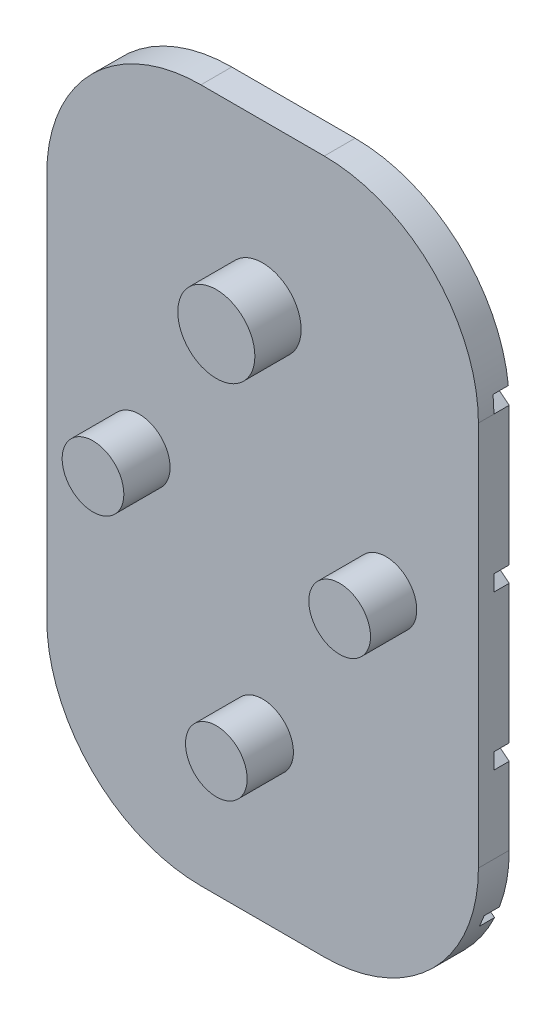
from build123d import *

# Parameters (mm, degrees)
CROQUIS1_R                = 2.5
CROQUIS1_R_2              = 2
SALIENTE_EXTRUIR1_DEPTH   = 2
CROQUIS2_R                = 2
SALIENTE_EXTRUIR2_DEPTH   = 3
SALIENTE_EXTRUIR2_2_DEPTH = 3
SALIENTE_EXTRUIR2_3_DEPTH = 3
CROQUIS2_R_2              = 2.5
SALIENTE_EXTRUIR2_4_DEPTH = 3
CORTAR_EXTRUIR1_DEPTH     = 1


with BuildPart() as part:
    # Croquis1 → Saliente-Extruir1 (new body)
    with BuildSketch(Plane.XY):
        with BuildLine():
            Line((-4, -22.5), (4, -22.5))
            ThreePointArc((4, -22.5), (11.071067812, -19.571067812), (14, -12.5))
            Line((14, -12.5), (14, 12.5))
            ThreePointArc((14, 12.5), (11.071067812, 19.571067812), (4, 22.5))
            Line((4, 22.5), (-4, 22.5))
            ThreePointArc((-4, 22.5), (-11.071067812, 19.571067812), (-14, 12.5))
            Line((-14, 12.5), (-14, -12.5))
            ThreePointArc((-14, -12.5), (-11.071067812, -19.571067812), (-4, -22.5))
        make_face()
        with Locations((0, 12)):
            Circle(CROQUIS1_R, mode=Mode.SUBTRACT)
        with Locations((0, -12)):
            Circle(CROQUIS1_R_2, mode=Mode.SUBTRACT)
        with Locations((-8, 0)):
            Circle(CROQUIS1_R_2, mode=Mode.SUBTRACT)
        with Locations((8, 0)):
            Circle(CROQUIS1_R_2, mode=Mode.SUBTRACT)
    extrude(amount=SALIENTE_EXTRUIR1_DEPTH)

    # Croquis3 → Cortar-Extruir1 (cut)
    with BuildSketch(Plane(origin=(0, 0, 0), x_dir=(-1, 0, 0), z_dir=(0, 0, -1))):
        with BuildLine():
            ThreePointArc((-13.941990851, 13.575554705), (-13.985487182, 13.038558953), (-14, 12.5))
            ThreePointArc((-14, 12.5), (0, 17.579936281), (14, 12.5))
            ThreePointArc((14, 12.5), (13.985487182, 13.038558953), (13.941990851, 13.575554705))
            ThreePointArc((13.941990851, 13.575554705), (0, 18.379936281), (-13.941990851, 13.575554705))
        make_face()
        with BuildLine():
            Line((-14, 3.530035327), (-14, 2.5))
            ThreePointArc((-14, 2.5), (0, 7.579936281), (14, 2.5))
            Line((14, 2.5), (14, 3.530035327))
            ThreePointArc((14, 3.530035327), (0, 8.379936281), (-14, 3.530035327))
        make_face()
        with BuildLine():
            Line((-14, -6.469964673), (-14, -7.5))
            ThreePointArc((-14, -7.5), (0, -2.420063719), (14, -7.5))
            Line((14, -7.5), (14, -6.469964673))
            ThreePointArc((14, -6.469964673), (0, -1.620063719), (-14, -6.469964673))
        make_face()
        with BuildLine():
            ThreePointArc((-1.978377069, -11.706701226), (-7.967927856, -13.069093159), (-13.370512288, -15.991919166))
            ThreePointArc((-13.370512288, -15.991919166), (-13.218824107, -16.374697677), (-13.051507373, -16.750907464))
            ThreePointArc((-13.051507373, -16.750907464), (-7.788018836, -13.856434527), (-1.934937817, -12.505979886))
            ThreePointArc((-1.934937817, -12.505979886), (-1.997052815, -12.108535966), (-1.978377069, -11.706701226))
        make_face()
        with BuildLine():
            ThreePointArc((13.370512288, -15.991919166), (7.967927856, -13.069093159), (1.978377069, -11.706701226))
            ThreePointArc((1.978377069, -11.706701226), (1.997052815, -12.108535966), (1.934937817, -12.505979886))
            ThreePointArc((1.934937817, -12.505979886), (7.788018836, -13.856434527), (13.051507373, -16.750907464))
            ThreePointArc((13.051507373, -16.750907464), (13.218824107, -16.374697677), (13.370512288, -15.991919166))
        make_face()
    extrude(amount=-CORTAR_EXTRUIR1_DEPTH, mode=Mode.SUBTRACT)


with BuildPart() as body_2:
    # Croquis2 → Saliente-Extruir2 (new body)
    with BuildSketch(Plane.XY.offset(2)):
        with Locations((8, 0)):
            Circle(CROQUIS2_R)
    extrude(amount=SALIENTE_EXTRUIR2_DEPTH)


with BuildPart() as body_3:
    # Croquis2 → Saliente-Extruir2 2 (new body)
    with BuildSketch(Plane.XY.offset(2)):
        with Locations((0, -12)):
            Circle(CROQUIS2_R)
    extrude(amount=SALIENTE_EXTRUIR2_2_DEPTH)


with BuildPart() as body_4:
    # Croquis2 → Saliente-Extruir2 3 (new body)
    with BuildSketch(Plane.XY.offset(2)):
        with Locations((-8, 0)):
            Circle(CROQUIS2_R)
    extrude(amount=SALIENTE_EXTRUIR2_3_DEPTH)


with BuildPart() as body_5:
    # Croquis2 → Saliente-Extruir2 4 (new body)
    with BuildSketch(Plane.XY.offset(2)):
        with Locations((0, 12)):
            Circle(CROQUIS2_R_2)
    extrude(amount=SALIENTE_EXTRUIR2_4_DEPTH)


solid = Compound([part.part, body_2.part, body_3.part, body_4.part, body_5.part])
